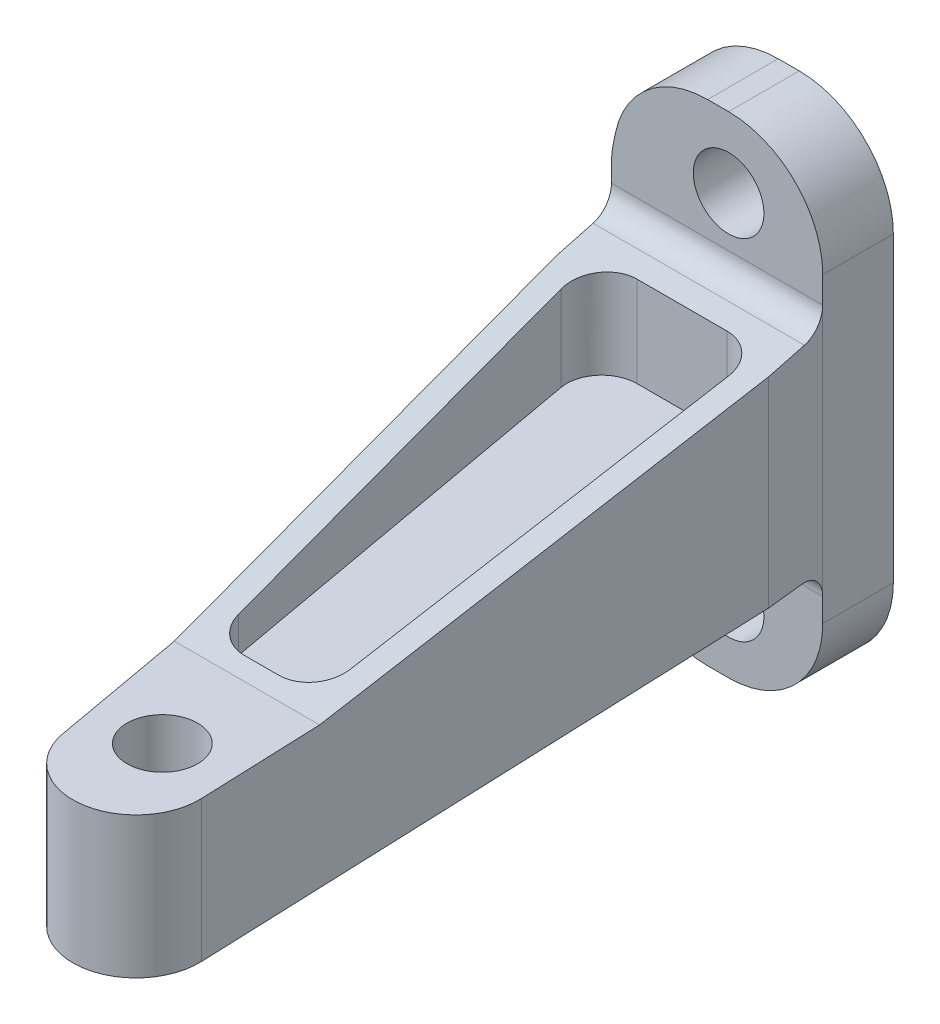
from build123d import *

# Parameters (mm, degrees)
SKETCH1_R           = 4.762499999999989
SKETCH1_R_2         = 4.762500000000005
BOSS_EXTRUDE1_DEPTH = 9.525
CHAMFER1_SIZE       = 88.89999999999999
CHAMFER1_SIZE2      = 6.20588556630559
CHAMFER2_SIZE       = 88.89999999999999
CHAMFER2_SIZE2      = 6.300746042301969
FILLET1_R           = 8.528649
CUT_EXTRUDE2_DEPTH  = 117.6635246642072
FILLET4_R           = 3.175
FILLET5_R           = 12.7
FILLET6_R           = 12.7
SKETCH15_R          = 4.762499999999997
CUT_EXTRUDE7_DEPTH  = 117.28166143642893
FILLET9_R           = 12.7
CUT_EXTRUDE8_DEPTH  = 15.760091062
CUT_EXTRUDE9_DEPTH  = 11.924211795


with BuildPart() as part:
    # Sketch1 → Boss-Extrude1 (new body)
    # profile 1 of 3: a face of its own
    with BuildSketch(Plane.XY):
        Polygon((-28.50000000000001, 23.36447913627793), (-28.500000000000007, 17.01447913627793), (-1.421e-14, 17.01447913627793), (-1.388e-14, 36.06447913627791), (-25.877441230163292, 36.06447913627793), align=None)
        with Locations(Location((-12.700000000000017, 26.539479136277926, 0), (0, 0, 180))):
            Circle(SKETCH1_R, mode=Mode.SUBTRACT)
    # profile 2 of 3: a face of its own
    with BuildSketch(Plane.XY):
        Polygon((1.421e-14, -11.046434023496033), (-28.499999999999996, -11.046434023496033), (-28.499999999999996, -17.396434023496035), (-25.877441230163278, -30.09643402349603), (1.421e-14, -30.09643402349603), align=None)
        with Locations(Location((-12.699999999999989, -20.571434023496032, 0), (0, 0, 180))):
            Circle(SKETCH1_R_2, mode=Mode.SUBTRACT)
    # profile 3 of 3: a face of its own
    with BuildSketch(Plane.XY):
        Polygon((-28.500000000000007, 17.01447913627793), (-28.5, -11.046434023496033), (1.421e-14, -11.046434023496033), (-5.89e-15, 17.014479136277927), align=None)
    extrude(amount=BOSS_EXTRUDE1_DEPTH)

    # Sweep1: sweep along a path in Sketch4
    with BuildLine(Plane(origin=(0, -11.046434023496033, 0), x_dir=(1, 0, 0), z_dir=(0, 1, 0))) as sweep1_path:
        Line((-14.249999999999991, -9.525), (-5.144041152540681, -93.4757286489478))
        Line((-5.144041152540681, -93.4757286489478), (-3.7745316583277084, -106.10167193035296))
    # Sketch3 → Sweep1 (sweep)
    with BuildSketch(Plane.XY.offset(9.525)):
        Polygon((-28.499999999999996, -11.046434023496033), (1.388e-14, -11.046434023496033), (-1.388e-14, 17.01447913627793), (-28.50000000000001, 17.01447913627793), align=None)
    sweep(path=sweep1_path.line)

    # Chamfer1
    chamfer1_edges = [part.edges().sort_by_distance(p)[0] for p in [
        (10.475468341672286, 2.9840225563909506, 106.10167193035296),
    ]]
    chamfer1_side = [part.faces().sort_by_distance(p)[0] for p in [
        (5.237734170836156, 2.9840225563909497, 57.813335965176485),
    ]]
    chamfer(chamfer1_edges, length=CHAMFER1_SIZE, length2=CHAMFER1_SIZE2, reference=chamfer1_side[0])

    # Chamfer2
    chamfer2_edges = [part.edges().sort_by_distance(p)[0] for p in [
        (-18.02453165832772, 2.984022556390949, 106.10167193035296),
    ]]
    chamfer2_side = [part.faces().sort_by_distance(p)[0] for p in [
        (-23.26226582916385, 2.9840225563909497, 57.813335965176506),
    ]]
    chamfer(chamfer2_edges, length=CHAMFER2_SIZE, length2=CHAMFER2_SIZE2, reference=chamfer2_side[0])

    # Fillet1
    fillet1_edges = [part.edges().sort_by_distance(p)[0] for p in [
        (4.269582775366721, 2.984022556390949, 106.10167193035296),
        (-11.72378561602573, 2.984022556390949, 106.10167193035296),
    ]]
    fillet(fillet1_edges, radius=FILLET1_R)

    # Sketch6 → Cut-Extrude2 (cut, through all)
    with BuildSketch(Plane.ZY.offset(28.500000000000004)):
        Polygon((106.10167193035296, -11.046434023496188), (93.47572864894777, -11.0464340234961), (80.70167193035297, -11.046434023496028), (114.70610576395035, -29.45752993708947), (128.32769329374543, 30.37810454166645), (17.720068960516624, 36.90132837728653), (9.525, 17.01447913627794), (80.70167193035296, 8.003565976503989), (106.10167193035296, 8.003565976503813), align=None)
    extrude(amount=-CUT_EXTRUDE2_DEPTH, mode=Mode.SUBTRACT)

    # Fillet4
    fillet4_edges = [part.edges().sort_by_distance(p)[0] for p in [
        (-14.249999999999995, -11.046434023496033, 9.525),
        (-14.25000000000001, 17.01447913627793, 9.525),
    ]]
    fillet(fillet4_edges, radius=FILLET4_R)

    # Fillet5
    fillet5_edges = [part.edges().sort_by_distance(p)[0] for p in [
        (-28.50000000000001, 23.36447913627793, 4.7625),
    ]]
    fillet(fillet5_edges, radius=FILLET5_R)

    # Fillet6
    fillet6_edges = [part.edges().sort_by_distance(p)[0] for p in [
        (-1.404e-14, 36.06447913627791, 4.7625),
        (-25.877441230163292, 36.06447913627793, 4.7625),
    ]]
    fillet(fillet6_edges, radius=FILLET6_R)

    # Sketch15 → Cut-Extrude7 (cut, through all)
    with BuildSketch(Plane(origin=(-2.72e-15, 8.00356597650455, 5.575e-14), x_dir=(1, 3.4e-16, -6e-17), z_dir=(-3.4e-16, 1, 6.99e-15))):
        with Locations(Location((-5.144041152540378, -93.47572864894777, 0), (0, 0, 270))):
            Circle(SKETCH15_R)
    extrude(amount=-CUT_EXTRUDE7_DEPTH, mode=Mode.SUBTRACT)

    # Fillet9
    fillet9_edges = [part.edges().sort_by_distance(p)[0] for p in [
        (1.404e-14, -30.09643402349603, 4.7625),
        (-25.877441230163278, -30.09643402349603, 4.7625),
        (-28.499999999999996, -17.396434023496035, 4.7625),
    ]]
    fillet(fillet9_edges, radius=FILLET9_R)

    # Sketch17 → Cut-Extrude8 (cut)
    with BuildSketch(Plane(origin=(0, 19.81286883339098, 0), x_dir=(1, 0, 0), z_dir=(0, 1, 0))):
        with BuildLine():
            Line((-23.794838845791546, -21.021241844192982), (-14.252419863558526, -74.10090839762722))
            add(Edge.make_bspline(
                [(-14.252419863558526, -74.10090839762722), (-13.55215795886545, -77.99611237791656), (-9.563905474722917, -77.99611237791653)],
                knots=[0.17649604429034987, 0.17649604429034987, 0.17649604429034987, 1.5707963267949046, 1.5707963267949046, 1.5707963267949046], degree=2, weights=[1, 0.7666750083054215, 1]))
            Line((-9.563905474722917, -77.99611237791653), (-4.929711575818474, -77.99611237791652))
            add(Edge.make_bspline(
                [(-4.929711575818474, -77.99611237791652), (0.01696199328928838, -77.99611237791657), (-0.17063766624835885, -73.09214006513507)],
                knots=[1.5707963267948917, 1.5707963267948917, 1.5707963267948917, 3.179526156898573, 3.179526156898573, 3.179526156898573], degree=2, weights=[1, 0.693568883905337, 1]))
            Line((-0.17063766624835885, -73.09214006513507), (-2.201180813451869, -20.012473511700826))
            add(Edge.make_bspline(
                [(-2.201180813451869, -20.012473511700826), (-2.3750711783370813, -15.466870726714172), (-6.960254723021984, -15.466870726714202)],
                knots=[0.03793350330876585, 0.03793350330876585, 0.03793350330876585, 1.5707963267949063, 1.5707963267949063, 1.5707963267949063], degree=2, weights=[1, 0.7203903131485674, 1]))
            Line((-6.960254723021984, -15.466870726714202), (-19.10632445695594, -15.466870726714204))
            add(Edge.make_bspline(
                [(-19.10632445695594, -15.466870726714204), (-24.79337820798673, -15.466870726714157), (-23.794838845791546, -21.021241844192982)],
                knots=[1.5707963267948915, 1.5707963267948915, 1.5707963267948915, 3.318088697880159, 3.318088697880159, 3.318088697880159], degree=2, weights=[1, 0.6420353819221085, 1]))
        make_face()
    extrude(amount=-CUT_EXTRUDE8_DEPTH, mode=Mode.SUBTRACT)

    # Sketch18 → Cut-Extrude9 (cut)
    with BuildSketch(Plane.XZ.offset(11.046434023496033)):
        with BuildLine():
            Line((-4.929711575818475, 77.99611237791653), (-9.563905474722917, 77.99611237791653))
            add(Edge.make_bspline(
                [(-9.563905474722917, 77.99611237791653), (-13.55215795886545, 77.99611237791656), (-14.252419863558526, 74.10090839762722)],
                knots=[4.712388980384682, 4.712388980384682, 4.712388980384682, 6.106689262889237, 6.106689262889237, 6.106689262889237], degree=2, weights=[1, 0.7666750083054213, 1]))
            Line((-14.252419863558526, 74.10090839762722), (-23.794838845791546, 21.021241844192982))
            add(Edge.make_bspline(
                [(-23.794838845791546, 21.021241844192982), (-24.79337820798673, 15.466870726714156), (-19.10632445695594, 15.466870726714204)],
                knots=[2.9650966092994273, 2.9650966092994273, 2.9650966092994273, 4.712388980384695, 4.712388980384695, 4.712388980384695], degree=2, weights=[1, 0.6420353819221084, 1]))
            Line((-19.10632445695594, 15.466870726714204), (-6.960254723021985, 15.466870726714204))
            add(Edge.make_bspline(
                [(-6.960254723021985, 15.466870726714204), (-2.3750711783370777, 15.46687072671417), (-2.201180813451869, 20.012473511700826)],
                knots=[4.71238898038468, 4.71238898038468, 4.71238898038468, 6.245251803870821, 6.245251803870821, 6.245251803870821], degree=2, weights=[1, 0.7203903131485672, 1]))
            Line((-2.201180813451869, 20.012473511700826), (-0.17063766624835808, 73.09214006513507))
            add(Edge.make_bspline(
                [(-0.17063766624835808, 73.09214006513507), (0.0169619932892866, 77.99611237791657), (-4.929711575818475, 77.99611237791653)],
                knots=[3.103659150281014, 3.103659150281014, 3.103659150281014, 4.712388980384695, 4.712388980384695, 4.712388980384695], degree=2, weights=[1, 0.693568883905337, 1]))
        make_face()
    extrude(amount=-CUT_EXTRUDE9_DEPTH, mode=Mode.SUBTRACT)


solid = part.part
